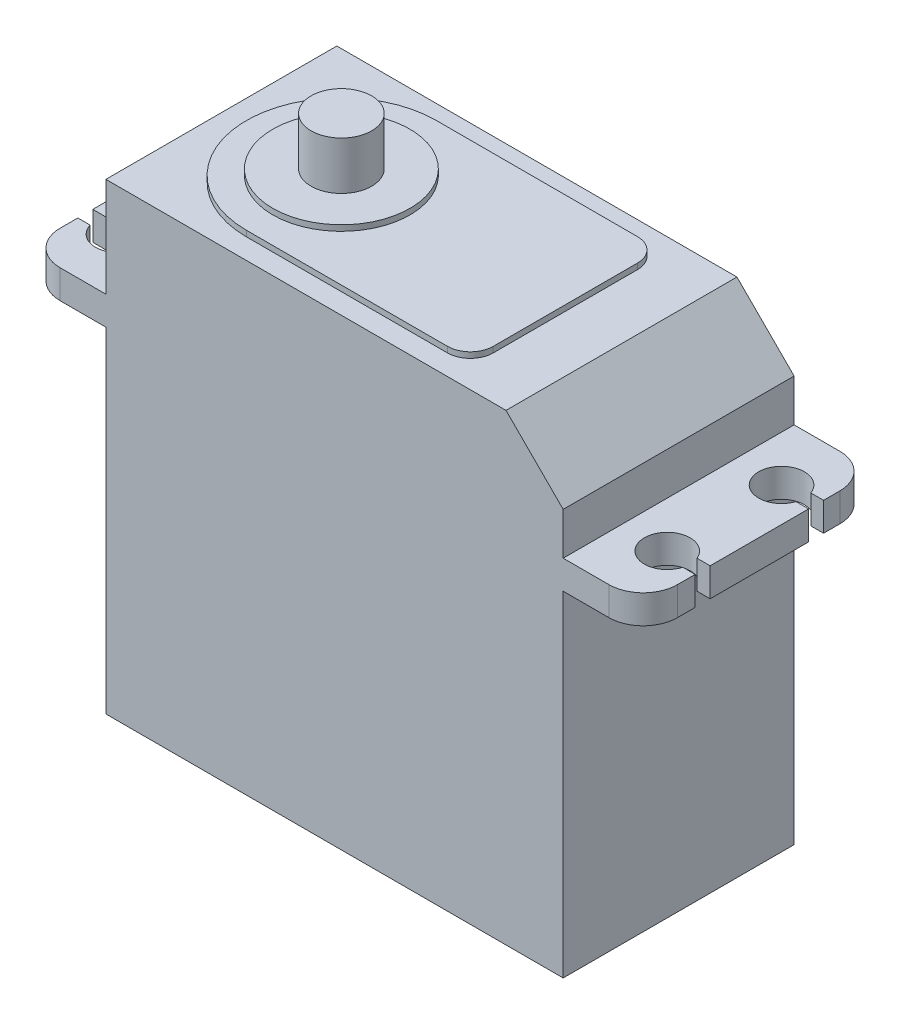
from build123d import *

# Parameters (mm, degrees)
SKETCH1_W           = 40
SKETCH1_H           = 29.3
SKETCH1_H_2         = 8.7
BOSS_EXTRUDE1_DEPTH = 20.2
SKETCH2_R           = 2.65
BOSS_EXTRUDE2_DEPTH = 5.2
SKETCH3_W           = 0.446843519
SKETCH3_H           = 1.306192745
SKETCH3_H_2         = 1.306192746
CUT_EXTRUDE1_DEPTH  = 5.2
FILLET1_R           = 3
CHAMFER1_SIZE       = 5
SKETCH4_R           = 6
BOSS_EXTRUDE3_DEPTH = 1
BOSS_EXTRUDE4_DEPTH = 0.5


with BuildPart() as part:
    # Sketch1 → Boss-Extrude1 (new body)
    with BuildSketch(Plane.XY):
        Rectangle(SKETCH1_W, SKETCH1_H)
        Polygon((-27, 14.65), (-20, 14.65), (20, 14.65), (27, 14.65), (27, 17.15), (20, 17.15), (-20, 17.15), (-27, 17.15), align=None)
        with Locations((0, 21.5)):
            Rectangle(SKETCH1_W, SKETCH1_H_2)
    extrude(amount=BOSS_EXTRUDE1_DEPTH)

    # Sketch2 → Boss-Extrude2 (add)
    with BuildSketch(Plane(origin=(0, 25.85, 0), x_dir=(1, 0, 0), z_dir=(0, 1, 0))):
        with Locations((-9.5, -10.1)):
            Circle(SKETCH2_R)
    extrude(amount=BOSS_EXTRUDE2_DEPTH)

    # Sketch3 → Cut-Extrude1 (cut)
    with BuildSketch(Plane(origin=(0, 17.15, 0), x_dir=(1, 0, 0), z_dir=(0, 1, 0))):
        with BuildLine():
            Line((-25.540550997, -5.731244645), (-25.540550997, -4.4250519))
            Line((-25.540550997, -4.4250519), (-25.882669663, -4.4250519))
            ThreePointArc((-25.882669663, -4.4250519), (-25.99986637, -5.076880711), (-25.897769796, -5.731244645))
            Line((-25.897769796, -5.731244645), (-25.540550997, -5.731244645))
        make_face()
        with BuildLine():
            Line((-25.882669663, -4.4250519), (-25.540550997, -4.4250519))
            Line((-25.540550997, -4.4250519), (-25.540550997, -5.731244645))
            Line((-25.540550997, -5.731244645), (-25.897769796, -5.731244645))
            ThreePointArc((-25.897769796, -5.731244645), (-23.680265416, -7.074277031), (-22, -5.1))
            ThreePointArc((-22, -5.1), (-23.657464839, -3.129550898), (-25.882669663, -4.4250519))
        make_face()
        with BuildLine():
            ThreePointArc((-25.897769796, -5.731244645), (-25.99986637, -5.076880711), (-25.882669663, -4.4250519))
            Line((-25.882669663, -4.4250519), (-27.446843519, -4.4250519))
            Line((-27.446843519, -4.4250519), (-27.446843519, -5.731244645))
            Line((-27.446843519, -5.731244645), (-25.897769796, -5.731244645))
        make_face()
        with BuildLine():
            Line((-25.540550997, -15.653096373), (-25.540550997, -14.346903627))
            Line((-25.540550997, -14.346903627), (-25.852794067, -14.346903627))
            ThreePointArc((-25.852794067, -14.346903627), (-25.997198696, -14.994182379), (-25.922000105, -15.653096373))
            Line((-25.922000105, -15.653096373), (-25.540550997, -15.653096373))
        make_face()
        with BuildLine():
            Line((-25.852794067, -14.346903627), (-25.540550997, -14.346903627))
            Line((-25.540550997, -14.346903627), (-25.540550997, -15.653096373))
            Line((-25.540550997, -15.653096373), (-25.922000105, -15.653096373))
            ThreePointArc((-25.922000105, -15.653096373), (-23.720715387, -17.080404026), (-22, -15.1))
            ThreePointArc((-22, -15.1), (-23.616325746, -13.137146448), (-25.852794067, -14.346903627))
        make_face()
        with BuildLine():
            ThreePointArc((-25.922000105, -15.653096373), (-25.997198696, -14.994182379), (-25.852794067, -14.346903627))
            Line((-25.852794067, -14.346903627), (-27.446843519, -14.346903627))
            Line((-27.446843519, -14.346903627), (-27.446843519, -15.653096373))
            Line((-27.446843519, -15.653096373), (-25.922000105, -15.653096373))
        make_face()
        with Locations((27.223421759, -5.078148273)):
            Rectangle(SKETCH3_W, SKETCH3_H)
        with BuildLine():
            ThreePointArc((26, -5.1), (25.974277031, -5.419734584), (25.897769796, -5.731244645))
            Line((25.897769796, -5.731244645), (27, -5.731244645))
            Line((27, -5.731244645), (27, -4.4250519))
            Line((27, -4.4250519), (25.882669663, -4.4250519))
            ThreePointArc((25.882669663, -4.4250519), (25.970449102, -4.757464839), (26, -5.1))
        make_face()
        with BuildLine():
            Line((25.540550997, -4.4250519), (25.540550997, -5.731244645))
            Line((25.540550997, -5.731244645), (25.897769796, -5.731244645))
            ThreePointArc((25.897769796, -5.731244645), (25.974277031, -5.419734584), (26, -5.1))
            ThreePointArc((26, -5.1), (25.970449102, -4.757464839), (25.882669663, -4.4250519))
            Line((25.882669663, -4.4250519), (25.540550997, -4.4250519))
        make_face()
        with BuildLine():
            Line((25.897769796, -5.731244645), (25.540550997, -5.731244645))
            Line((25.540550997, -5.731244645), (25.540550997, -4.4250519))
            Line((25.540550997, -4.4250519), (25.882669663, -4.4250519))
            ThreePointArc((25.882669663, -4.4250519), (22.00013363, -5.123119289), (25.897769796, -5.731244645))
        make_face()
        with Locations((27.223421759, -15)):
            Rectangle(SKETCH3_W, SKETCH3_H_2)
        with BuildLine():
            Line((27, -15.653096373), (27, -14.346903627))
            Line((27, -14.346903627), (25.852794067, -14.346903627))
            ThreePointArc((25.852794067, -14.346903627), (25.962853552, -14.716325746), (26, -15.1))
            ThreePointArc((26, -15.1), (25.980404026, -15.379284613), (25.922000105, -15.653096373))
            Line((25.922000105, -15.653096373), (27, -15.653096373))
        make_face()
        with BuildLine():
            ThreePointArc((26, -15.1), (25.962853552, -14.716325746), (25.852794067, -14.346903627))
            Line((25.852794067, -14.346903627), (25.540550997, -14.346903627))
            Line((25.540550997, -14.346903627), (25.540550997, -15.653096373))
            Line((25.540550997, -15.653096373), (25.922000105, -15.653096373))
            ThreePointArc((25.922000105, -15.653096373), (25.980404026, -15.379284613), (26, -15.1))
        make_face()
        with BuildLine():
            Line((25.540550997, -14.346903627), (25.852794067, -14.346903627))
            ThreePointArc((25.852794067, -14.346903627), (22.002801304, -15.205817621), (25.922000105, -15.653096373))
            Line((25.922000105, -15.653096373), (25.540550997, -15.653096373))
            Line((25.540550997, -15.653096373), (25.540550997, -14.346903627))
        make_face()
    extrude(amount=-CUT_EXTRUDE1_DEPTH, mode=Mode.SUBTRACT)

    # Fillet1
    fillet1_edges = [part.edges().sort_by_distance(p)[0] for p in [
        (-27, 15.9, 0),
        (27, 15.9, 0),
        (27, 15.9, 20.2),
        (-27, 15.9, 20.2),
    ]]
    fillet(fillet1_edges, radius=FILLET1_R)

    # Chamfer1
    chamfer1_edges = [part.edges().sort_by_distance(p)[0] for p in [
        (20, 25.85, 10.1),
    ]]
    chamfer(chamfer1_edges, length=CHAMFER1_SIZE)

    # Sketch4 → Boss-Extrude3 (add)
    with BuildSketch(Plane(origin=(0, 25.85, 0), x_dir=(1, 0, 0), z_dir=(0, 1, 0))):
        with Locations((-9.5, -10.1)):
            Circle(SKETCH4_R)
    extrude(amount=BOSS_EXTRUDE3_DEPTH)

    # Sketch5 → Boss-Extrude4 (add)
    with BuildSketch(Plane(origin=(0, 25.85, 0), x_dir=(1, 0, 0), z_dir=(0, 1, 0))):
        with BuildLine():
            Line((-9.5, -1.789920634), (8.092095239, -1.789920634))
            ThreePointArc((8.092095239, -1.789920634), (9.506308801, -2.375707072), (10.092095239, -3.789920634))
            Line((10.092095239, -3.789920634), (10.092095239, -16.410079366))
            ThreePointArc((10.092095239, -16.410079366), (9.506308801, -17.824292928), (8.092095239, -18.410079366))
            Line((8.092095239, -18.410079366), (-9.5, -18.410079366))
            ThreePointArc((-9.5, -18.410079366), (-17.810079366, -10.1), (-9.5, -1.789920634))
        make_face()
    extrude(amount=BOSS_EXTRUDE4_DEPTH)


solid = part.part
